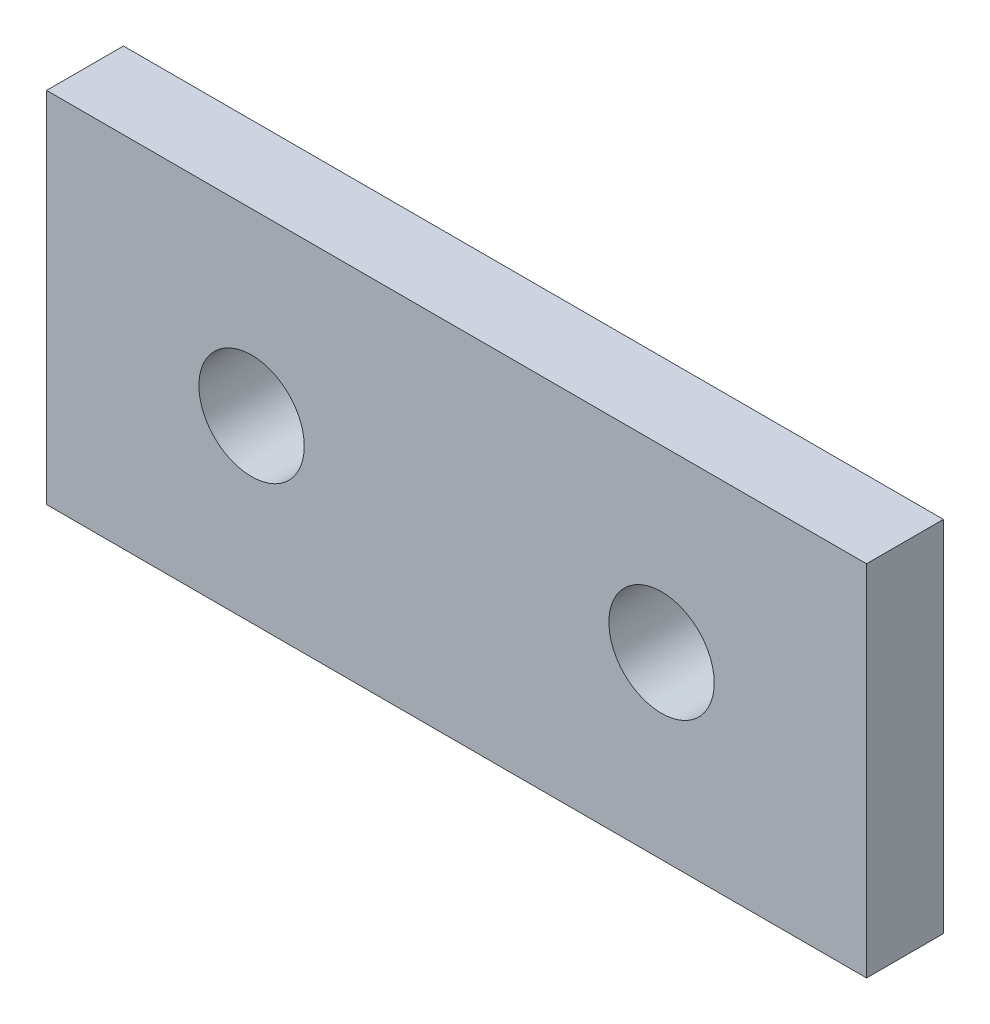
from build123d import *

# Parameters (mm, degrees)
SKETCH1_W      = 50.8
SKETCH1_H      = 22.225
SKETCH1_R      = 3.2639
EXTRUDE1_DEPTH = 4.7625


with BuildPart() as part:
    # Sketch1 → Extrude1 (new body)
    with BuildSketch(Plane.XY):
        Rectangle(SKETCH1_W, SKETCH1_H)
        with Locations((12.7, 0)):
            Circle(SKETCH1_R, mode=Mode.SUBTRACT)
        with Locations((-12.7, 0)):
            Circle(SKETCH1_R, mode=Mode.SUBTRACT)
    extrude(amount=-EXTRUDE1_DEPTH)


solid = part.part
